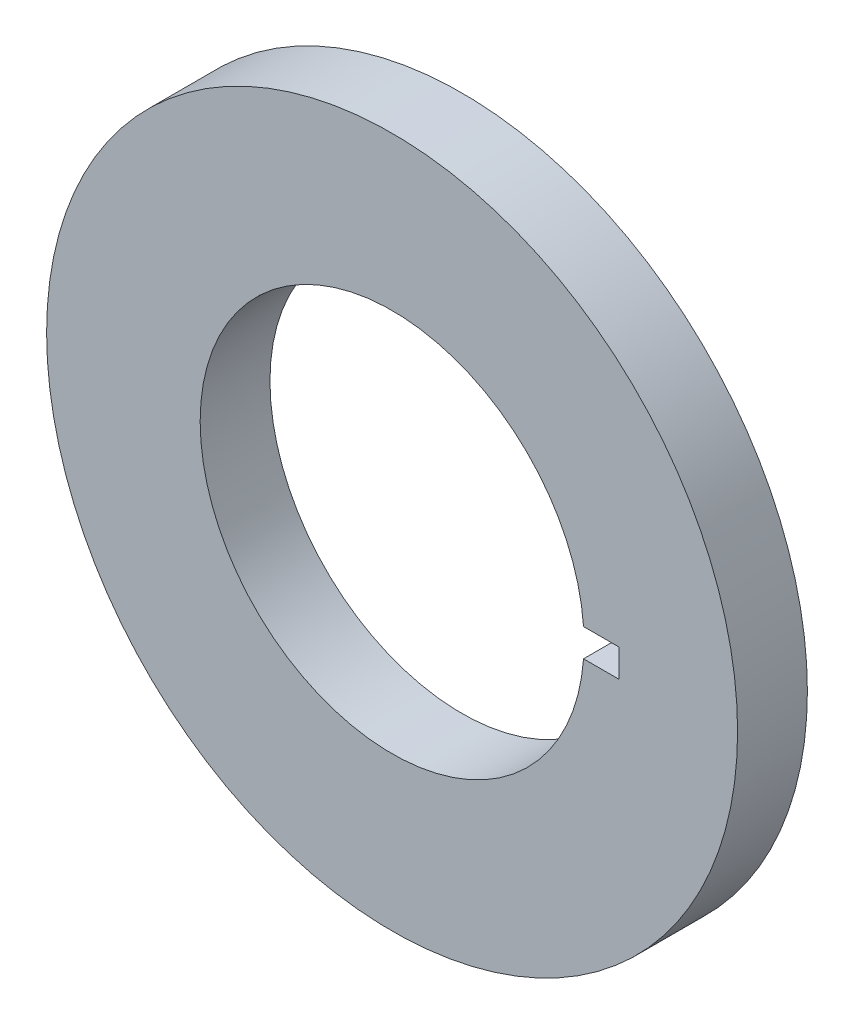
from build123d import *

# Parameters (mm, degrees)
SKETCH1_R           = 49.5
SKETCH1_R_2         = 27.5
BOSS_EXTRUDE1_DEPTH = 10
SKETCH2_W           = 10
SKETCH2_H           = 4
CUT_EXTRUDE1_DEPTH  = 11


with BuildPart() as part:
    # Sketch1 → Boss-Extrude1 (new body)
    with BuildSketch(Plane.XY):
        Circle(SKETCH1_R)
        Circle(SKETCH1_R_2, mode=Mode.SUBTRACT)
    extrude(amount=BOSS_EXTRUDE1_DEPTH)

    # Sketch2 → Cut-Extrude1 (cut, through all)
    with BuildSketch(Plane.XY.offset(10)):
        with Locations((27.5, 0)):
            Rectangle(SKETCH2_W, SKETCH2_H)
    extrude(amount=-CUT_EXTRUDE1_DEPTH, mode=Mode.SUBTRACT)


solid = part.part
